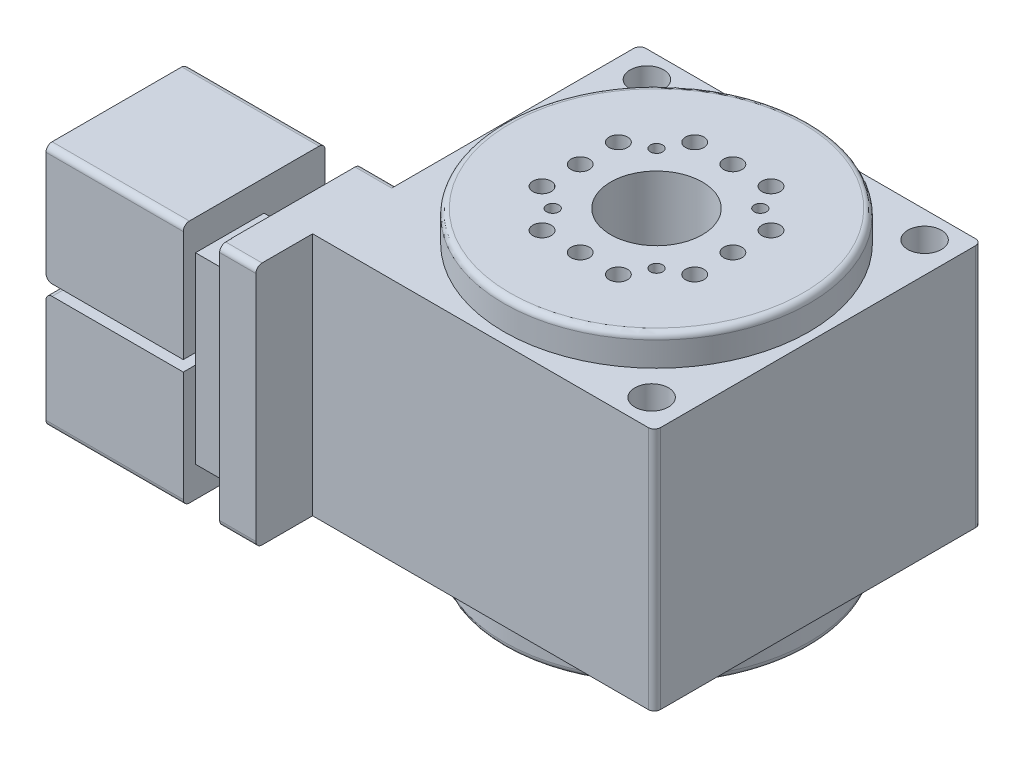
from build123d import *

# Parameters (mm, degrees)
SKETCH_1_R               = 50
EXTRUDE_1_DEPTH          = 80
FILLET_1_R               = 2
SKETCH_2_R               = 5.5
CUT_EXTRUDE_1_DEPTH      = 80
SKETCH_3_W               = 11.906162192
SKETCH_3_H               = 92.178298694
CUT_EXTRUDE_2_DEPTH      = 4
SKETCH_4_W               = 11.810184272
SKETCH_4_H               = 42.447784179
CUT_EXTRUDE_3_DEPTH      = 10
SKETCH_5_W               = 11.942044514
SKETCH_5_H               = 45.487816108
CUT_EXTRUDE_4_DEPTH      = 10
SKETCH_6_W               = 11.810184272
SKETCH_6_H               = 60.078318052
CUT_EXTRUDE_5_DEPTH      = 20
CUT_EXTRUDE_7_DEPTH      = 50
FILLET_2_R               = 2
SKETCH_8_R               = 50
EXTRUDE_2_DEPTH          = 90
SKETCH_9_R               = 50
EXTRUDE_3_DEPTH          = 100
FILLET_3_R               = 2
SKETCH_10_R              = 15
CUT_EXTRUDE_8_DEPTH      = 100
SKETCH_11_R              = 3
CUT_EXTRUDE_9_DEPTH      = 10
PATTERN_CIRCULAR_1_COUNT = 4
SKETCH_12_R              = 3
CUT_EXTRUDE_10_DEPTH     = 10
PATTERN_CIRCULAR_2_COUNT = 4
SKETCH_13_R              = 2
CUT_EXTRUDE_11_DEPTH     = 10
PATTERN_CIRCULAR_3_COUNT = 4
SKETCH_14_R              = 2
CUT_EXTRUDE_12_DEPTH     = 10


with BuildPart() as part:
    # 草图1 → 凸台-拉伸1 (new body)
    with BuildSketch(Plane(origin=(0, 0, 0), x_dir=(1, 0, 0), z_dir=(0, 1, 0))):
        Polygon((-59.119808165, 53.642938728), (52.826892357, 53.642938728), (52.826892357, -53.523119778), (-59.119808165, -53.523119778), (-59.119808165, -72.079800299), (-127.882584058, -72.079800299), (-127.882584058, -25.63201612), (-59.119808165, -25.63201612), align=None)
        Circle(SKETCH_1_R, mode=Mode.SUBTRACT)
    extrude(amount=EXTRUDE_1_DEPTH)

    # 圆角1
    fillet_1_edges = [part.edges().sort_by_distance(p)[0] for p in [
        (-93.501196111, 0, 25.63201612),
        (-93.501196111, 80, 72.079800299),
        (-59.119808165, 40, -53.642938728),
        (52.826892357, 40, -53.642938728),
        (52.826892357, 40, 53.523119778),
        (-127.882584058, 40, 25.63201612),
        (-93.501196111, 80, 25.63201612),
        (-93.501196111, 0, 72.079800299),
    ]]
    fillet(fillet_1_edges, radius=FILLET_1_R)

    # 草图2 → 切除-拉伸1 (cut)
    with BuildSketch(Plane(origin=(0, 80, 0), x_dir=(1, 0, 0), z_dir=(0, 1, 0))):
        with Locations((-48.119582726, 44.979282561)):
            Circle(SKETCH_2_R)
        with Locations((42.826400195, 44.979282561)):
            Circle(SKETCH_2_R)
        with Locations((42.826400195, -44.420910434)):
            Circle(SKETCH_2_R)
    extrude(amount=-CUT_EXTRUDE_1_DEPTH, mode=Mode.SUBTRACT)

    # 草图3 → 切除-拉伸2 (cut)
    with BuildSketch(Plane.XY.offset(72.079800299)):
        with Locations((-76.966233581, 38.147560985)):
            Rectangle(SKETCH_3_W, SKETCH_3_H)
    extrude(amount=-CUT_EXTRUDE_2_DEPTH, mode=Mode.SUBTRACT)

    # 草图4 → 切除-拉伸3 (cut)
    with BuildSketch(Plane(origin=(0, 80, 0), x_dir=(1, 0, 0), z_dir=(0, 1, 0))):
        with Locations((-77.014222541, -46.85590821)):
            Rectangle(SKETCH_4_W, SKETCH_4_H)
    extrude(amount=-CUT_EXTRUDE_3_DEPTH, mode=Mode.SUBTRACT)

    # 草图5 → 切除-拉伸4 (cut)
    with BuildSketch(Plane.XZ):
        with Locations((-76.94829242, 45.335892245)):
            Rectangle(SKETCH_5_W, SKETCH_5_H)
    extrude(amount=-CUT_EXTRUDE_4_DEPTH, mode=Mode.SUBTRACT)

    # 草图6 → 切除-拉伸5 (cut)
    with BuildSketch(Plane(origin=(0, 0, 25.63201612), x_dir=(-1, 0, 0), z_dir=(0, 0, -1))):
        with Locations((77.014222541, 39.960840974)):
            Rectangle(SKETCH_6_W, SKETCH_6_H)
    extrude(amount=-CUT_EXTRUDE_5_DEPTH, mode=Mode.SUBTRACT)

    # 草图7 → 切除-拉伸7 (cut)
    with BuildSketch(Plane(origin=(0, 0, 25.63201612), x_dir=(-1, 0, 0), z_dir=(0, 0, -1))):
        Polygon((125.882584058, 41.670977544), (82.919314677, 41.670977544), (82.919314677, 38.149415643), (125.882584058, 38.149415643), (132.648981097, 38.149415643), (132.648981097, 41.670977544), align=None)
    extrude(amount=-CUT_EXTRUDE_7_DEPTH, mode=Mode.SUBTRACT)

    # 圆角2
    fillet_2_edges = [part.edges().sort_by_distance(p)[0] for p in [
        (-127.882584058, 38.149415643, 49.855908209),
        (-127.882584058, 41.670977544, 49.855908209),
        (-104.400949368, 38.149415643, 25.63201612),
        (-104.400949368, 41.670977544, 25.63201612),
        (-127.29679762, 38.149415643, 26.217802557),
        (-127.29679762, 41.670977544, 26.217802557),
    ]]
    fillet(fillet_2_edges, radius=FILLET_2_R)

    # 草图8 → 凸台-拉伸2 (add)
    with BuildSketch(Plane(origin=(0, 0, 0), x_dir=(1, 0, 0), z_dir=(0, 1, 0))):
        Circle(SKETCH_8_R)
    extrude(amount=EXTRUDE_2_DEPTH)

    # 草图9 → 凸台-拉伸3 (add)
    with BuildSketch(Plane(origin=(0, 90, 0), x_dir=(1, 0, 0), z_dir=(0, 1, 0))):
        Circle(SKETCH_9_R)
    extrude(amount=-EXTRUDE_3_DEPTH)

    # 圆角3
    fillet_3_edges = [part.edges().sort_by_distance(p)[0] for p in [
        (-50, 90, 0),
        (-50, -10, 0),
    ]]
    fillet(fillet_3_edges, radius=FILLET_3_R)

    # 草图10 → 切除-拉伸8 (cut)
    with BuildSketch(Plane.XZ.offset(10)):
        Circle(SKETCH_10_R)
    extrude(amount=-CUT_EXTRUDE_8_DEPTH, mode=Mode.SUBTRACT)

    # 草图11 → 切除-拉伸9 (cut)
    with BuildSketch(Plane.XZ.offset(10)):
        with Locations((25, 0)):
            Circle(SKETCH_11_R)
        with Locations((25, 12.5)):
            Circle(SKETCH_11_R)
        with Locations((25, -12.5)):
            Circle(SKETCH_11_R)
    cut_extrude_9 = extrude(amount=-CUT_EXTRUDE_9_DEPTH, mode=Mode.SUBTRACT)

    # 阵列(圆周)1: 切除-拉伸9 ×4 about axis
    pattern_circular_1_axis = Axis((0, 0, 0), (0, 1, 0))
    for i in range(1, PATTERN_CIRCULAR_1_COUNT):
        add(cut_extrude_9.rotate(pattern_circular_1_axis, i * 360 / PATTERN_CIRCULAR_1_COUNT), mode=Mode.SUBTRACT)

    # 草图12 → 切除-拉伸10 (cut)
    with BuildSketch(Plane(origin=(0, 90, 0), x_dir=(1, 0, 0), z_dir=(0, 1, 0))):
        with Locations((-12.5, 25)):
            Circle(SKETCH_12_R)
        with Locations((0, 25)):
            Circle(SKETCH_12_R)
        with Locations((12.5, 25)):
            Circle(SKETCH_12_R)
    cut_extrude_10 = extrude(amount=-CUT_EXTRUDE_10_DEPTH, mode=Mode.SUBTRACT)

    # 阵列(圆周)2: 切除-拉伸10 ×4 about axis
    pattern_circular_2_axis = Axis((0, 0, 0), (0, 1, 0))
    for i in range(1, PATTERN_CIRCULAR_2_COUNT):
        add(cut_extrude_10.rotate(pattern_circular_2_axis, i * 360 / PATTERN_CIRCULAR_2_COUNT), mode=Mode.SUBTRACT)

    # 草图13 → 切除-拉伸11 (cut)
    with BuildSketch(Plane.XZ.offset(10)):
        with Locations((17, 17)):
            Circle(SKETCH_13_R)
    cut_extrude_11 = extrude(amount=-CUT_EXTRUDE_11_DEPTH, mode=Mode.SUBTRACT)

    # 阵列(圆周)3: 切除-拉伸11 ×4 about axis
    pattern_circular_3_axis = Axis((0, 0, 0), (0, 1, 0))
    for i in range(1, PATTERN_CIRCULAR_3_COUNT):
        add(cut_extrude_11.rotate(pattern_circular_3_axis, i * 360 / PATTERN_CIRCULAR_3_COUNT), mode=Mode.SUBTRACT)

    # 草图14 → 切除-拉伸12 (cut)
    with BuildSketch(Plane(origin=(0, 90, 0), x_dir=(1, 0, 0), z_dir=(0, 1, 0))):
        with Locations((-17, -17)):
            Circle(SKETCH_14_R)
        with Locations((-17, 17)):
            Circle(SKETCH_14_R)
        with Locations((17, 17)):
            Circle(SKETCH_14_R)
        with Locations((17, -17)):
            Circle(SKETCH_14_R)
    extrude(amount=-CUT_EXTRUDE_12_DEPTH, mode=Mode.SUBTRACT)


solid = part.part
